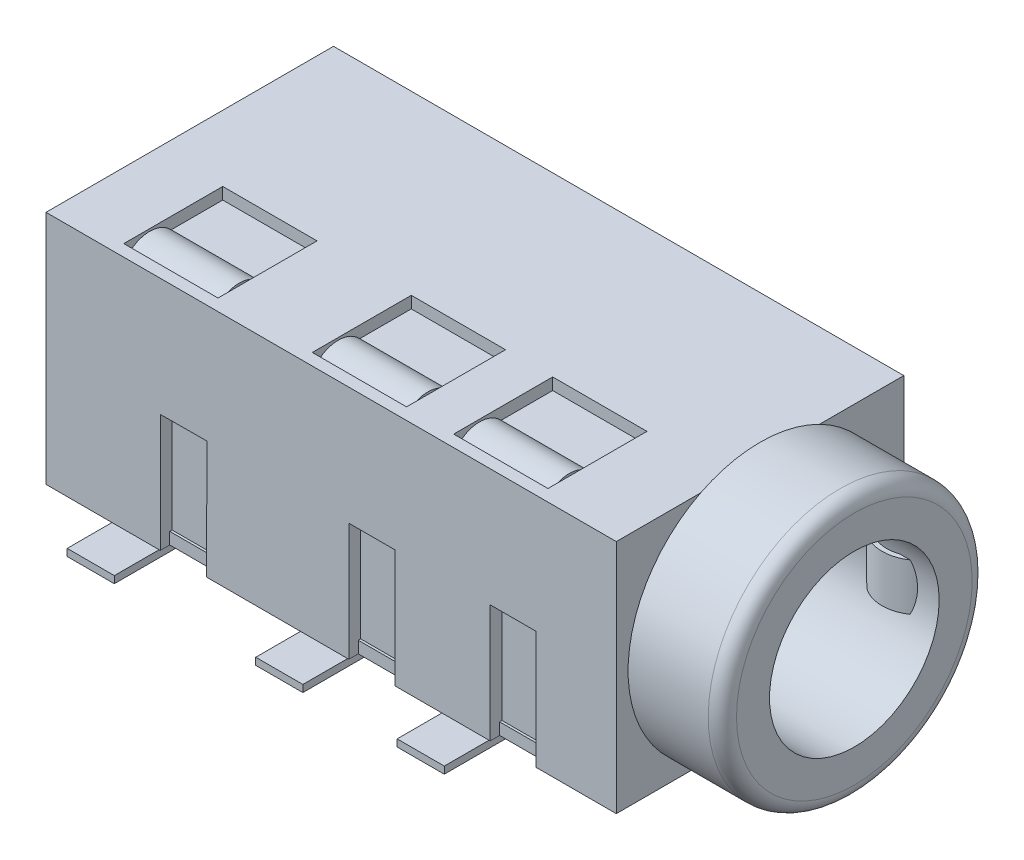
from build123d import *

# Parameters (mm, degrees)
SKETCH1_W           = 12.1
SKETCH1_H           = 6.1
BOSS_EXTRUDE1_DEPTH = 5
SKETCH2_R           = 2.8
BOSS_EXTRUDE2_DEPTH = 2
SKETCH3_R           = 1.8
CUT_EXTRUDE1_DEPTH  = 14
SKETCH4_W           = 1
SKETCH4_H           = 2
BOSS_EXTRUDE3_DEPTH = 0.15
SKETCH5_W           = 0.975
SKETCH5_H           = 2.5
CUT_EXTRUDE2_DEPTH  = 0.25
SKETCH7_W           = 0.975
SKETCH7_H           = 2.5
CUT_EXTRUDE4_DEPTH  = 0.25
SKETCH8_W           = 2
SKETCH8_H           = 2.1
CUT_EXTRUDE5_DEPTH  = 0.25
EXTRUDE_THIN1_START = -1.75
EXTRUDE_THIN1_DEPTH = 1.9
LPATTERN1_COUNT     = 2
LPATTERN1_PITCH     = 3
LPATTERN2_COUNT     = 2
LPATTERN2_PITCH     = 7
SKETCH13_W          = 1
SKETCH13_H          = 0.25
BOSS_EXTRUDE4_DEPTH = 0.05
SKETCH14_W          = 1
SKETCH14_H          = 0.25
BOSS_EXTRUDE5_DEPTH = 0.05
FILLET1_R           = 0.3
EXTRUDE_THIN3_START = -3
EXTRUDE_THIN3_DEPTH = 1


with BuildPart() as part:
    # Sketch1 → Boss-Extrude1 (new body)
    with BuildSketch(Plane(origin=(0, 0, 0), x_dir=(1, 0, 0), z_dir=(0, 1, 0))):
        with Locations((6.05, 3.05)):
            Rectangle(SKETCH1_W, SKETCH1_H)
    extrude(amount=BOSS_EXTRUDE1_DEPTH)

    # Sketch2 → Boss-Extrude2 (add)
    with BuildSketch(Plane(origin=(12.1, 0, 0), x_dir=(0, 0, -1), z_dir=(1, 0, 0))):
        with Locations((3.05, 2.5)):
            Circle(SKETCH2_R)
    extrude(amount=BOSS_EXTRUDE2_DEPTH)

    # Sketch3 → Cut-Extrude1 (cut)
    with BuildSketch(Plane(origin=(14.1, 0, 0), x_dir=(0, 0, -1), z_dir=(1, 0, 0))):
        with Locations((3.05, 2.5)):
            Circle(SKETCH3_R)
    extrude(amount=-CUT_EXTRUDE1_DEPTH, mode=Mode.SUBTRACT)

    # Sketch4 → Boss-Extrude3 (add)
    with BuildSketch(Plane.XZ):
        with Locations((5.9, -0.05)):
            Rectangle(SKETCH4_W, SKETCH4_H)
        with Locations((8.9, -0.05)):
            Rectangle(SKETCH4_W, SKETCH4_H)
        with Locations((1.9, -0.05)):
            Rectangle(SKETCH4_W, SKETCH4_H)
        with Locations((1.404811666, -6.05)):
            Rectangle(SKETCH4_W, SKETCH4_H)
    extrude(amount=BOSS_EXTRUDE3_DEPTH)

    # Sketch5 → Cut-Extrude2 (cut)
    with BuildSketch(Plane.XY):
        Polygon((3.4, 0), (3.419751258, 2.5), (3.420317054, 2.504399254), (2.425, 2.5), (2.425, 0), align=None)
        with Locations((9.9125, 1.25)):
            Rectangle(SKETCH5_W, SKETCH5_H)
        with Locations((6.9125, 1.25)):
            Rectangle(SKETCH5_W, SKETCH5_H)
    extrude(amount=-CUT_EXTRUDE2_DEPTH, mode=Mode.SUBTRACT)

    # Sketch7 → Cut-Extrude4 (cut)
    with BuildSketch(Plane(origin=(0, 0, -6.1), x_dir=(-1, 0, 0), z_dir=(0, 0, -1))):
        with Locations((-2.417311666, 1.25)):
            Rectangle(SKETCH7_W, SKETCH7_H)
    extrude(amount=-CUT_EXTRUDE4_DEPTH, mode=Mode.SUBTRACT)

    # Sketch8 → Cut-Extrude5 (cut)
    with BuildSketch(Plane(origin=(0, 5, 0), x_dir=(1, 0, 0), z_dir=(0, 1, 0))):
        with Locations((2.4, 1.3)):
            Rectangle(SKETCH8_W, SKETCH8_H)
        with Locations((6.4, 1.3)):
            Rectangle(SKETCH8_W, SKETCH8_H)
        with Locations((9.4, 1.3)):
            Rectangle(SKETCH8_W, SKETCH8_H)
    extrude(amount=-CUT_EXTRUDE5_DEPTH, mode=Mode.SUBTRACT)

    # Sketch13 → Boss-Extrude4 (add)
    with BuildSketch(Plane.XY.offset(-0.25)):
        Polygon((2.4, 0), (2.4, 0.25), (3.401975126, 0.25), (3.4, 0), align=None)
        with Locations((6.9, 0.125)):
            Rectangle(SKETCH13_W, SKETCH13_H)
        with Locations((9.9, 0.125)):
            Rectangle(SKETCH13_W, SKETCH13_H)
    extrude(amount=BOSS_EXTRUDE4_DEPTH)

    # Sketch14 → Boss-Extrude5 (add)
    with BuildSketch(Plane(origin=(0, 0, -5.85), x_dir=(-1, 0, 0), z_dir=(0, 0, -1))):
        with Locations((-2.404811666, 0.125)):
            Rectangle(SKETCH14_W, SKETCH14_H)
    extrude(amount=BOSS_EXTRUDE5_DEPTH)

    # Fillet1
    fillet1_edges = [part.edges().sort_by_distance(p)[0] for p in [
        (14.1, 2.5, -0.25),
    ]]
    fillet(fillet1_edges, radius=FILLET1_R)

    # Sketch15 → Extrude-Thin3 (add)
    with BuildSketch(Plane(origin=(0, 5, 0), x_dir=(1, 0, 0), z_dir=(0, 1, 0)).offset(EXTRUDE_THIN3_START)):
        with BuildLine():
            ThreePointArc((12.596452416, 4.947159755), (13.098067378, 4.739384034), (13.599682341, 4.947159755))
            Line((13.599682341, 4.947159755), (13.670393019, 4.876449076))
            ThreePointArc((13.670393019, 4.876449076), (13.098067378, 4.639384034), (12.525741738, 4.876449076))
            Line((12.525741738, 4.876449076), (12.596452416, 4.947159755))
        make_face()
    extrude(amount=EXTRUDE_THIN3_DEPTH)


with BuildPart() as body_2:
    # Sketch10 → Extrude-Thin1 (new body)
    with BuildSketch(Plane(origin=(12.1, 0, 0), x_dir=(0, 0, -1), z_dir=(1, 0, 0)).offset(EXTRUDE_THIN1_START)):
        with BuildLine():
            ThreePointArc((0.25, 4.747640047), (0.749761668, 5), (1.249523336, 4.747640047))
            Line((1.249523336, 4.747640047), (1.169050579, 4.688275619))
            ThreePointArc((1.169050579, 4.688275619), (0.749761668, 4.9), (0.330472757, 4.688275619))
            Line((0.330472757, 4.688275619), (0.25, 4.747640047))
        make_face()
    extrude_thin1 = extrude(amount=-EXTRUDE_THIN1_DEPTH)


with BuildPart() as lpattern1_1:
    # LPattern1: Extrude-Thin1 ×2
    with Locations(*[(-i * LPATTERN1_PITCH, 0, 0) for i in range(1, LPATTERN1_COUNT)]):
        add(extrude_thin1)


with BuildPart() as lpattern2_1:
    # LPattern2: Extrude-Thin1 ×2
    with Locations(*[(-i * LPATTERN2_PITCH, 0, 0) for i in range(1, LPATTERN2_COUNT)]):
        add(extrude_thin1)


solid = Compound([part.part, body_2.part, lpattern1_1.part, lpattern2_1.part])
